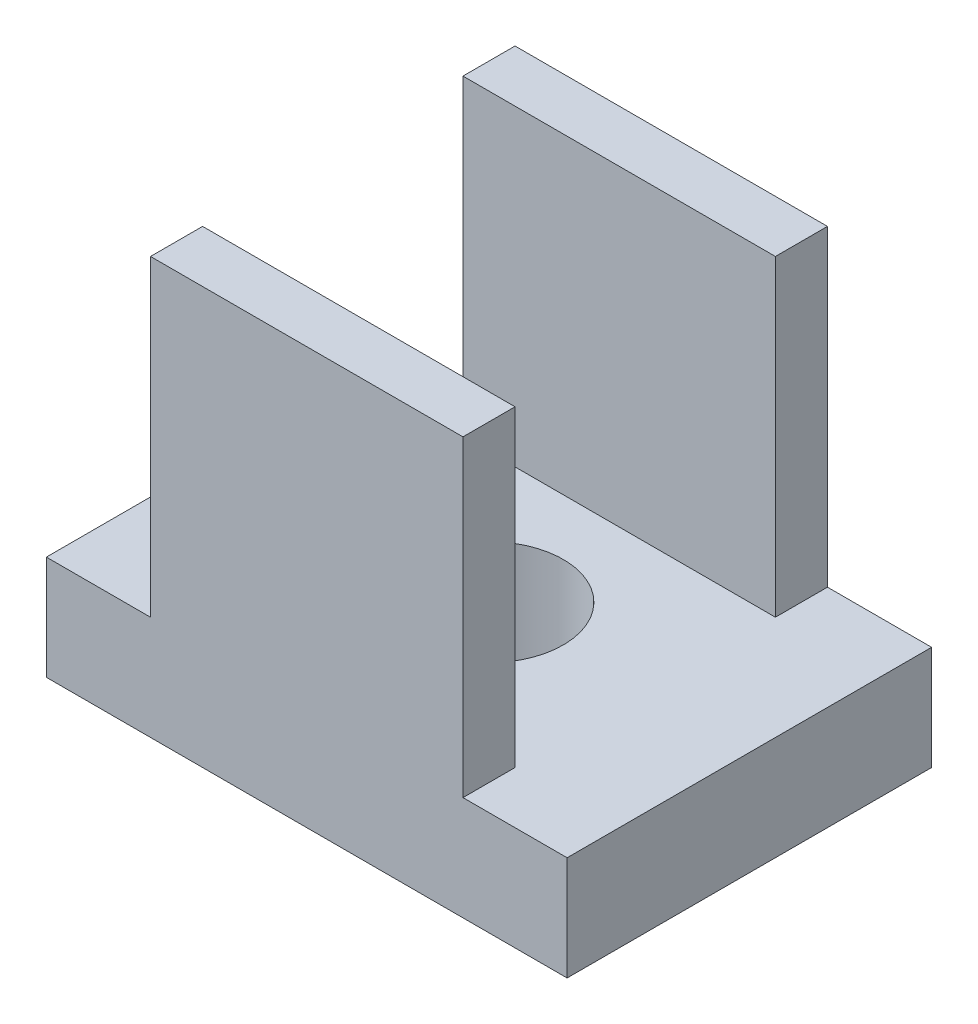
from build123d import *

# Parameters (mm, degrees)
SKETCH1_W           = 10
SKETCH1_H           = 7
BOSS_EXTRUDE1_DEPTH = 2
SKETCH2_R           = 1.425
CUT_EXTRUDE1_DEPTH  = 3
SKETCH3_W           = 6
SKETCH3_H           = 1
BOSS_EXTRUDE2_DEPTH = 6


with BuildPart() as part:
    # Sketch1 → Boss-Extrude1 (new body)
    with BuildSketch(Plane(origin=(0, 0, 0), x_dir=(1, 0, 0), z_dir=(0, 1, 0))):
        Rectangle(SKETCH1_W, SKETCH1_H)
    extrude(amount=BOSS_EXTRUDE1_DEPTH)

    # Sketch2 → Cut-Extrude1 (cut, through all)
    with BuildSketch(Plane(origin=(0, 2, 0), x_dir=(1, 0, 0), z_dir=(0, 1, 0))):
        Circle(SKETCH2_R)
    extrude(amount=-CUT_EXTRUDE1_DEPTH, mode=Mode.SUBTRACT)

    # Sketch3 → Boss-Extrude2 (add)
    with BuildSketch(Plane(origin=(0, 2, 0), x_dir=(1, 0, 0), z_dir=(0, 1, 0))):
        with Locations((0, 3)):
            Rectangle(SKETCH3_W, SKETCH3_H)
        with Locations((0, -3)):
            Rectangle(SKETCH3_W, SKETCH3_H)
    extrude(amount=BOSS_EXTRUDE2_DEPTH)


solid = part.part
